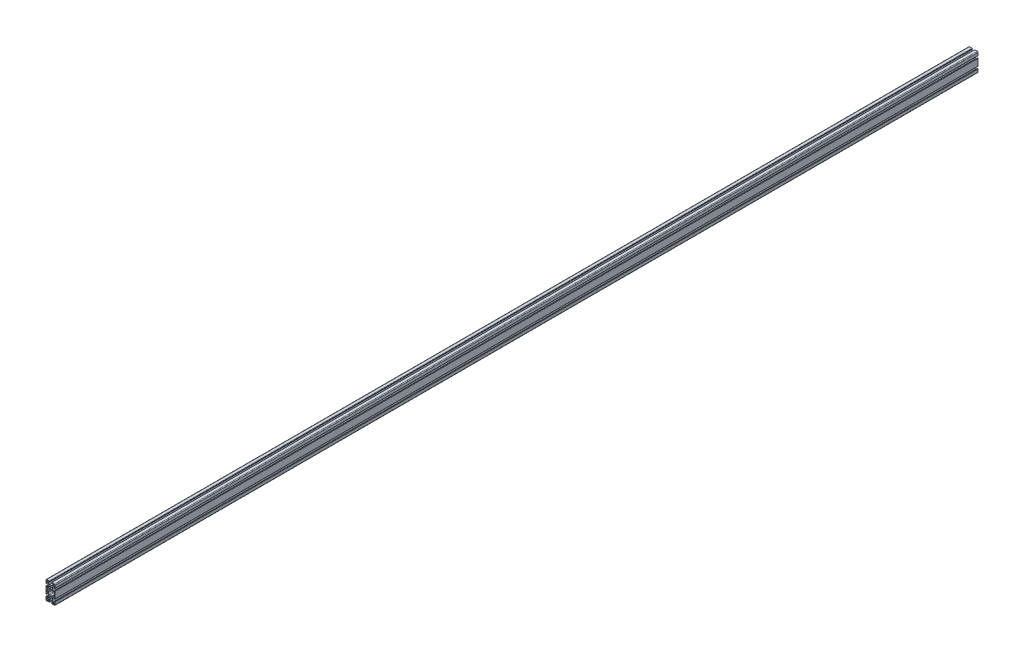
from build123d import *

# Parameters (mm, degrees)
SKETCH1_R           = 3.4
SKETCH1_R_2         = 3.25
BOSS_EXTRUDE1_DEPTH = 4000


with BuildPart() as part:
    # Sketch1 → Boss-Extrude1 (new body)
    with BuildSketch(Plane(origin=(0, 0, -4000), x_dir=(-1, 0, 0), z_dir=(0, 0, -1))):
        with BuildLine():
            Line((18.51966974, 35.94), (17.80484913, 35.94))
            ThreePointArc((17.80484913, 35.94), (16.486201664, 35.393798336), (15.94, 34.07515087))
            Line((15.94, 34.07515087), (15.94, 32.71927308))
            Line((15.94, 32.71927308), (16.7, 32.71927308))
            Line((16.7, 32.71927308), (16.7, 31.05167256))
            ThreePointArc((16.7, 31.05167256), (16.308497671, 30.106502329), (15.36332744, 29.715))
            Line((15.36332744, 29.715), (12.987102448, 29.715))
            ThreePointArc((12.987102448, 29.715), (12.646514194, 29.782747216), (12.357777413, 29.975674965))
            Line((12.357777413, 29.975674965), (9.091242789, 33.242209589))
            ThreePointArc((9.091242789, 33.242209589), (8.061572221, 34.783220495), (7.7, 36.600966799))
            Line((7.7, 36.600966799), (7.7, 43.399033201))
            ThreePointArc((7.7, 43.399033201), (8.061572221, 45.216779505), (9.091242789, 46.757790411))
            Line((9.091242789, 46.757790411), (12.357777413, 50.024325035))
            ThreePointArc((12.357777413, 50.024325035), (12.646514194, 50.217252784), (12.987102448, 50.285))
            Line((12.987102448, 50.285), (15.36332744, 50.285))
            ThreePointArc((15.36332744, 50.285), (16.308497671, 49.893497671), (16.7, 48.94832744))
            Line((16.7, 48.94832744), (16.7, 47.28072692))
            Line((16.7, 47.28072692), (15.94, 47.28072692))
            Line((15.94, 47.28072692), (15.94, 45.92484913))
            ThreePointArc((15.94, 45.92484913), (16.486201664, 44.606201664), (17.80484913, 44.06))
            Line((17.80484913, 44.06), (18.51966974, 44.06))
            ThreePointArc((18.51966974, 44.06), (19.566421305, 44.493578695), (20, 45.54033026))
            Line((20, 45.54033026), (20, 56.83))
            ThreePointArc((20, 56.83), (19.071528496, 59.071528496), (16.83, 60))
            Line((16.83, 60), (5.6299228, 60))
            ThreePointArc((5.6299228, 60), (4.519765154, 59.540157646), (4.0599228, 58.43))
            Line((4.0599228, 58.43), (4.0599228, 57.51))
            ThreePointArc((4.0599228, 57.51), (4.519765154, 56.399842354), (5.6299228, 55.94))
            Line((5.6299228, 55.94), (6.6963329, 55.94))
            Line((6.6963329, 55.94), (6.6963329, 56.71502222))
            Line((6.6963329, 56.71502222), (9.0199228, 56.71502222))
            ThreePointArc((9.0199228, 56.71502222), (9.917948412, 56.343047832), (10.2899228, 55.44502222))
            Line((10.2899228, 55.44502222), (10.2899228, 52.992025248))
            ThreePointArc((10.2899228, 52.992025248), (10.222175584, 52.651436994), (10.029247835, 52.362700213))
            Line((10.029247835, 52.362700213), (6.581173831, 48.914626209))
            ThreePointArc((6.581173831, 48.914626209), (5.040162925, 47.884955641), (3.222416621, 47.52338342))
            Line((3.222416621, 47.52338342), (-3.222416621, 47.52338342))
            ThreePointArc((-3.222416621, 47.52338342), (-5.040162925, 47.884955641), (-6.581173831, 48.914626209))
            Line((-6.581173831, 48.914626209), (-10.029247835, 52.362700213))
            ThreePointArc((-10.029247835, 52.362700213), (-10.222175584, 52.651436994), (-10.2899228, 52.992025248))
            Line((-10.2899228, 52.992025248), (-10.2899228, 55.44502222))
            ThreePointArc((-10.2899228, 55.44502222), (-9.917948412, 56.343047832), (-9.0199228, 56.71502222))
            Line((-9.0199228, 56.71502222), (-6.6963329, 56.71502222))
            Line((-6.6963329, 56.71502222), (-6.6963329, 55.94))
            Line((-6.6963329, 55.94), (-5.6299228, 55.94))
            ThreePointArc((-5.6299228, 55.94), (-4.519765154, 56.399842354), (-4.0599228, 57.51))
            Line((-4.0599228, 57.51), (-4.0599228, 58.43))
            ThreePointArc((-4.0599228, 58.43), (-4.519765154, 59.540157646), (-5.6299228, 60))
            Line((-5.6299228, 60), (-16.83, 60))
            ThreePointArc((-16.83, 60), (-19.071528496, 59.071528496), (-20, 56.83))
            Line((-20, 56.83), (-20, 45.54033026))
            ThreePointArc((-20, 45.54033026), (-19.566421305, 44.493578695), (-18.51966974, 44.06))
            Line((-18.51966974, 44.06), (-17.80484913, 44.06))
            ThreePointArc((-17.80484913, 44.06), (-16.486201664, 44.606201664), (-15.94, 45.92484913))
            Line((-15.94, 45.92484913), (-15.94, 47.28072692))
            Line((-15.94, 47.28072692), (-16.7, 47.28072692))
            Line((-16.7, 47.28072692), (-16.7, 48.94832744))
            ThreePointArc((-16.7, 48.94832744), (-16.308497671, 49.893497671), (-15.36332744, 50.285))
            Line((-15.36332744, 50.285), (-12.987102448, 50.285))
            ThreePointArc((-12.987102448, 50.285), (-12.646514194, 50.217252784), (-12.357777413, 50.024325035))
            Line((-12.357777413, 50.024325035), (-9.091242789, 46.757790411))
            ThreePointArc((-9.091242789, 46.757790411), (-8.061572221, 45.216779505), (-7.7, 43.399033201))
            Line((-7.7, 43.399033201), (-7.7, 36.600966799))
            ThreePointArc((-7.7, 36.600966799), (-8.061572221, 34.783220495), (-9.091242789, 33.242209589))
            Line((-9.091242789, 33.242209589), (-12.357777413, 29.975674965))
            ThreePointArc((-12.357777413, 29.975674965), (-12.646514194, 29.782747216), (-12.987102448, 29.715))
            Line((-12.987102448, 29.715), (-15.36332744, 29.715))
            ThreePointArc((-15.36332744, 29.715), (-16.308497671, 30.106502329), (-16.7, 31.05167256))
            Line((-16.7, 31.05167256), (-16.7, 32.71927308))
            Line((-16.7, 32.71927308), (-15.94, 32.71927308))
            Line((-15.94, 32.71927308), (-15.94, 34.07515087))
            ThreePointArc((-15.94, 34.07515087), (-16.486201664, 35.393798336), (-17.80484913, 35.94))
            Line((-17.80484913, 35.94), (-18.51966974, 35.94))
            ThreePointArc((-18.51966974, 35.94), (-19.566421305, 35.506421305), (-20, 34.45966974))
            Line((-20, 34.45966974), (-20, 5.54033026))
            ThreePointArc((-20, 5.54033026), (-19.566421305, 4.493578695), (-18.51966974, 4.06))
            Line((-18.51966974, 4.06), (-17.80484913, 4.06))
            ThreePointArc((-17.80484913, 4.06), (-16.486201664, 4.606201664), (-15.94, 5.92484913))
            Line((-15.94, 5.92484913), (-15.94, 7.28072692))
            Line((-15.94, 7.28072692), (-16.7, 7.28072692))
            Line((-16.7, 7.28072692), (-16.7, 9.015))
            ThreePointArc((-16.7, 9.015), (-16.328025612, 9.913025612), (-15.43, 10.285))
            Line((-15.43, 10.285), (-12.987102448, 10.285))
            ThreePointArc((-12.987102448, 10.285), (-12.646514194, 10.217252784), (-12.357777413, 10.024325035))
            Line((-12.357777413, 10.024325035), (-9.091242789, 6.757790411))
            ThreePointArc((-9.091242789, 6.757790411), (-8.061572221, 5.216779505), (-7.7, 3.399033201))
            Line((-7.7, 3.399033201), (-7.7, -3.399033201))
            ThreePointArc((-7.7, -3.399033201), (-8.061572221, -5.216779505), (-9.091242789, -6.757790411))
            Line((-9.091242789, -6.757790411), (-12.357777413, -10.024325035))
            ThreePointArc((-12.357777413, -10.024325035), (-12.646514194, -10.217252784), (-12.987102448, -10.285))
            Line((-12.987102448, -10.285), (-15.36332744, -10.285))
            ThreePointArc((-15.36332744, -10.285), (-16.308497671, -9.893497671), (-16.7, -8.94832744))
            Line((-16.7, -8.94832744), (-16.7, -7.28072692))
            Line((-16.7, -7.28072692), (-15.94, -7.28072692))
            Line((-15.94, -7.28072692), (-15.94, -5.92484913))
            ThreePointArc((-15.94, -5.92484913), (-16.486201664, -4.606201664), (-17.80484913, -4.06))
            Line((-17.80484913, -4.06), (-18.51966974, -4.06))
            ThreePointArc((-18.51966974, -4.06), (-19.566421305, -4.493578695), (-20, -5.54033026))
            Line((-20, -5.54033026), (-20, -16.83))
            ThreePointArc((-20, -16.83), (-19.071528496, -19.071528496), (-16.83, -20))
            Line((-16.83, -20), (-5.6299228, -20))
            ThreePointArc((-5.6299228, -20), (-4.519765154, -19.540157646), (-4.0599228, -18.43))
            Line((-4.0599228, -18.43), (-4.0599228, -17.51))
            ThreePointArc((-4.0599228, -17.51), (-4.519765154, -16.399842354), (-5.6299228, -15.94))
            Line((-5.6299228, -15.94), (-6.6963329, -15.94))
            Line((-6.6963329, -15.94), (-6.6963329, -16.71502222))
            Line((-6.6963329, -16.71502222), (-9.0199228, -16.71502222))
            ThreePointArc((-9.0199228, -16.71502222), (-9.917948412, -16.343047832), (-10.2899228, -15.44502222))
            Line((-10.2899228, -15.44502222), (-10.2899228, -12.992025248))
            ThreePointArc((-10.2899228, -12.992025248), (-10.222175584, -12.651436994), (-10.029247835, -12.362700213))
            Line((-10.029247835, -12.362700213), (-6.581173831, -8.914626209))
            ThreePointArc((-6.581173831, -8.914626209), (-5.040162925, -7.884955641), (-3.222416621, -7.52338342))
            Line((-3.222416621, -7.52338342), (3.222416621, -7.52338342))
            ThreePointArc((3.222416621, -7.52338342), (5.040162925, -7.884955641), (6.581173831, -8.914626209))
            Line((6.581173831, -8.914626209), (10.029247835, -12.362700213))
            ThreePointArc((10.029247835, -12.362700213), (10.222175584, -12.651436994), (10.2899228, -12.992025248))
            Line((10.2899228, -12.992025248), (10.2899228, -15.30245607))
            ThreePointArc((10.2899228, -15.30245607), (9.917948412, -16.200481682), (9.0199228, -16.57245607))
            Line((9.0199228, -16.57245607), (6.8402736, -16.57245607))
            Line((6.8402736, -16.57245607), (6.8402736, -15.94))
            Line((6.8402736, -15.94), (5.6299228, -15.94))
            ThreePointArc((5.6299228, -15.94), (4.519765154, -16.399842354), (4.0599228, -17.51))
            Line((4.0599228, -17.51), (4.0599228, -18.43))
            ThreePointArc((4.0599228, -18.43), (4.519765154, -19.540157646), (5.6299228, -20))
            Line((5.6299228, -20), (16.83, -20))
            ThreePointArc((16.83, -20), (19.071528496, -19.071528496), (20, -16.83))
            Line((20, -16.83), (20, -5.54033026))
            ThreePointArc((20, -5.54033026), (19.566421305, -4.493578695), (18.51966974, -4.06))
            Line((18.51966974, -4.06), (17.80484913, -4.06))
            ThreePointArc((17.80484913, -4.06), (16.486201664, -4.606201664), (15.94, -5.92484913))
            Line((15.94, -5.92484913), (15.94, -7.28072692))
            Line((15.94, -7.28072692), (16.7, -7.28072692))
            Line((16.7, -7.28072692), (16.7, -8.94832744))
            ThreePointArc((16.7, -8.94832744), (16.308497671, -9.893497671), (15.36332744, -10.285))
            Line((15.36332744, -10.285), (12.987102448, -10.285))
            ThreePointArc((12.987102448, -10.285), (12.646514194, -10.217252784), (12.357777413, -10.024325035))
            Line((12.357777413, -10.024325035), (9.091242789, -6.757790411))
            ThreePointArc((9.091242789, -6.757790411), (8.061572221, -5.216779505), (7.7, -3.399033201))
            Line((7.7, -3.399033201), (7.7, 3.399033201))
            ThreePointArc((7.7, 3.399033201), (8.061572221, 5.216779505), (9.091242789, 6.757790411))
            Line((9.091242789, 6.757790411), (12.357777413, 10.024325035))
            ThreePointArc((12.357777413, 10.024325035), (12.646514194, 10.217252784), (12.987102448, 10.285))
            Line((12.987102448, 10.285), (15.43, 10.285))
            ThreePointArc((15.43, 10.285), (16.328025612, 9.913025612), (16.7, 9.015))
            Line((16.7, 9.015), (16.7, 7.28072692))
            Line((16.7, 7.28072692), (15.94, 7.28072692))
            Line((15.94, 7.28072692), (15.94, 5.92484913))
            ThreePointArc((15.94, 5.92484913), (16.486201664, 4.606201664), (17.80484913, 4.06))
            Line((17.80484913, 4.06), (18.51966974, 4.06))
            ThreePointArc((18.51966974, 4.06), (19.566421305, 4.493578695), (20, 5.54033026))
            Line((20, 5.54033026), (20, 34.45966974))
            ThreePointArc((20, 34.45966974), (19.566421305, 35.506421305), (18.51966974, 35.94))
        make_face()
        Circle(SKETCH1_R, mode=Mode.SUBTRACT)
        with Locations((0, 40)):
            Circle(SKETCH1_R_2, mode=Mode.SUBTRACT)
        with BuildLine():
            Line((18.3499228, 55.5500772), (18.3499228, 52.5700772))
            ThreePointArc((18.3499228, 52.5700772), (18.165400072, 52.124599928), (17.7199228, 51.9400772))
            Line((17.7199228, 51.9400772), (13.2099228, 51.9400772))
            ThreePointArc((13.2099228, 51.9400772), (12.311897188, 52.312051588), (11.9399228, 53.2100772))
            Line((11.9399228, 53.2100772), (11.9399228, 57.7200772))
            ThreePointArc((11.9399228, 57.7200772), (12.124445528, 58.165554472), (12.5699228, 58.3500772))
            Line((12.5699228, 58.3500772), (15.5499228, 58.3500772))
            ThreePointArc((15.5499228, 58.3500772), (17.529821787, 57.529976187), (18.3499228, 55.5500772))
        make_face(mode=Mode.SUBTRACT)
        with BuildLine():
            Line((18.3499228, -12.5700772), (18.3499228, -15.5500772))
            ThreePointArc((18.3499228, -15.5500772), (17.529821787, -17.529976187), (15.5499228, -18.3500772))
            Line((15.5499228, -18.3500772), (12.5699228, -18.3500772))
            ThreePointArc((12.5699228, -18.3500772), (12.124445528, -18.165554472), (11.9399228, -17.7200772))
            Line((11.9399228, -17.7200772), (11.9399228, -13.2100772))
            ThreePointArc((11.9399228, -13.2100772), (12.311897188, -12.312051588), (13.2099228, -11.9400772))
            Line((13.2099228, -11.9400772), (17.7199228, -11.9400772))
            ThreePointArc((17.7199228, -11.9400772), (18.165400072, -12.124599928), (18.3499228, -12.5700772))
        make_face(mode=Mode.SUBTRACT)
        with BuildLine():
            Line((16.7, 25.17944515), (16.7, 14.82055485))
            ThreePointArc((16.7, 14.82055485), (16.328025612, 13.922529238), (15.43, 13.55055485))
            Line((15.43, 13.55055485), (11.743153696, 13.55055485))
            ThreePointArc((11.743153696, 13.55055485), (11.257145737, 13.453881856), (10.845128084, 13.178580462))
            Line((10.845128084, 13.178580462), (6.581173831, 8.914626209))
            ThreePointArc((6.581173831, 8.914626209), (5.040162925, 7.884955641), (3.222416621, 7.52338342))
            Line((3.222416621, 7.52338342), (-3.222416621, 7.52338342))
            ThreePointArc((-3.222416621, 7.52338342), (-5.040162925, 7.884955641), (-6.581173831, 8.914626209))
            Line((-6.581173831, 8.914626209), (-10.845128084, 13.178580462))
            ThreePointArc((-10.845128084, 13.178580462), (-11.257145737, 13.453881856), (-11.743153696, 13.55055485))
            Line((-11.743153696, 13.55055485), (-15.43, 13.55055485))
            ThreePointArc((-15.43, 13.55055485), (-16.328025612, 13.922529238), (-16.7, 14.82055485))
            Line((-16.7, 14.82055485), (-16.7, 25.17944515))
            ThreePointArc((-16.7, 25.17944515), (-16.328025612, 26.077470762), (-15.43, 26.44944515))
            Line((-15.43, 26.44944515), (-11.743153696, 26.44944515))
            ThreePointArc((-11.743153696, 26.44944515), (-11.257145737, 26.546118144), (-10.845128084, 26.821419538))
            Line((-10.845128084, 26.821419538), (-6.581173831, 31.085373791))
            ThreePointArc((-6.581173831, 31.085373791), (-5.040162925, 32.115044359), (-3.222416621, 32.47661658))
            Line((-3.222416621, 32.47661658), (3.222416621, 32.47661658))
            ThreePointArc((3.222416621, 32.47661658), (5.040162925, 32.115044359), (6.581173831, 31.085373791))
            Line((6.581173831, 31.085373791), (10.845128084, 26.821419538))
            ThreePointArc((10.845128084, 26.821419538), (11.257145737, 26.546118144), (11.743153696, 26.44944515))
            Line((11.743153696, 26.44944515), (15.43, 26.44944515))
            ThreePointArc((15.43, 26.44944515), (16.328025612, 26.077470762), (16.7, 25.17944515))
        make_face(mode=Mode.SUBTRACT)
        with BuildLine():
            Line((-11.9399228, 57.7200772), (-11.9399228, 53.2100772))
            ThreePointArc((-11.9399228, 53.2100772), (-12.311897188, 52.312051588), (-13.2099228, 51.9400772))
            Line((-13.2099228, 51.9400772), (-17.7199228, 51.9400772))
            ThreePointArc((-17.7199228, 51.9400772), (-18.165400072, 52.124599928), (-18.3499228, 52.5700772))
            Line((-18.3499228, 52.5700772), (-18.3499228, 55.5500772))
            ThreePointArc((-18.3499228, 55.5500772), (-17.529821787, 57.529976187), (-15.5499228, 58.3500772))
            Line((-15.5499228, 58.3500772), (-12.5699228, 58.3500772))
            ThreePointArc((-12.5699228, 58.3500772), (-12.124445528, 58.165554472), (-11.9399228, 57.7200772))
        make_face(mode=Mode.SUBTRACT)
        with BuildLine():
            Line((-11.9399228, -13.2100772), (-11.9399228, -17.7200772))
            ThreePointArc((-11.9399228, -17.7200772), (-12.124445528, -18.165554472), (-12.5699228, -18.3500772))
            Line((-12.5699228, -18.3500772), (-15.5499228, -18.3500772))
            ThreePointArc((-15.5499228, -18.3500772), (-17.529821787, -17.529976187), (-18.3499228, -15.5500772))
            Line((-18.3499228, -15.5500772), (-18.3499228, -12.5700772))
            ThreePointArc((-18.3499228, -12.5700772), (-18.165400072, -12.124599928), (-17.7199228, -11.9400772))
            Line((-17.7199228, -11.9400772), (-13.2099228, -11.9400772))
            ThreePointArc((-13.2099228, -11.9400772), (-12.311897188, -12.312051588), (-11.9399228, -13.2100772))
        make_face(mode=Mode.SUBTRACT)
    extrude(amount=-BOSS_EXTRUDE1_DEPTH)


solid = part.part
